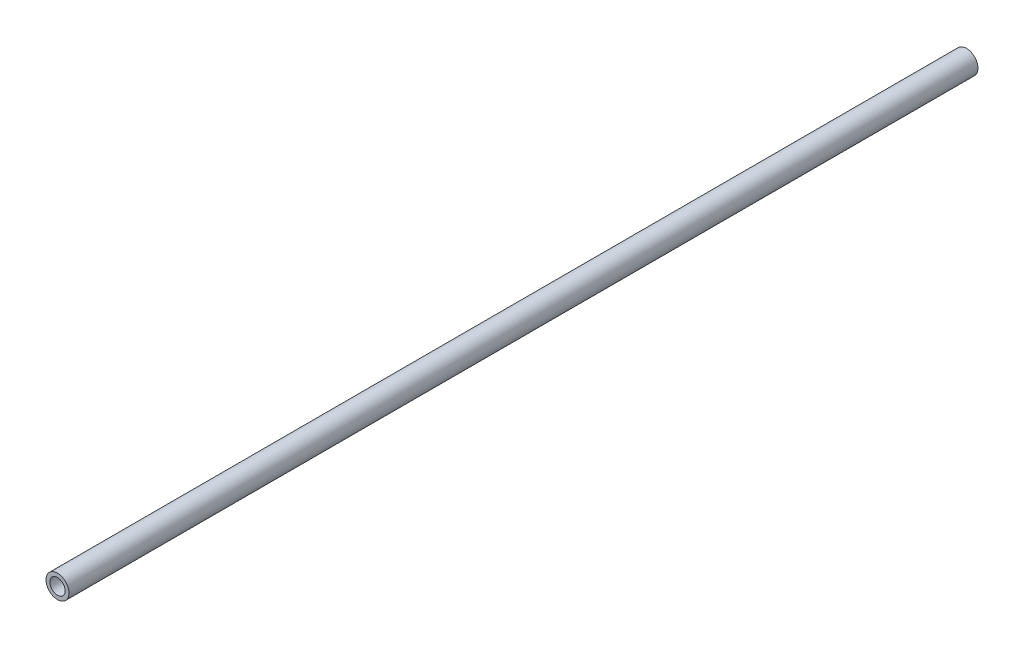
from build123d import *

# Parameters (mm, degrees)
SZKIC1_R                    = 12
SZKIC1_R_2                  = 8
DODANIE_WYCI_GNI_CIE1_DEPTH = 948


with BuildPart() as part:
    # Szkic1 → Dodanie-wyciągnięcie1 (new body)
    with BuildSketch(Plane.XY):
        Circle(SZKIC1_R)
        Circle(SZKIC1_R_2, mode=Mode.SUBTRACT)
    extrude(amount=DODANIE_WYCI_GNI_CIE1_DEPTH)


solid = part.part
